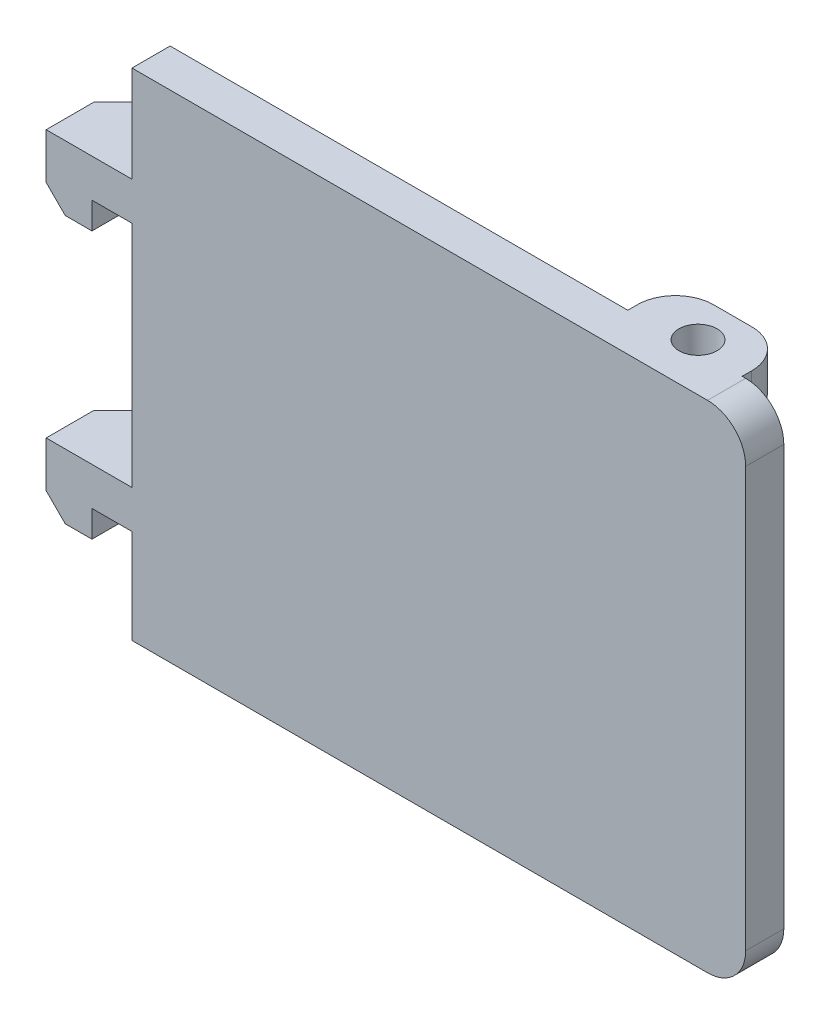
from build123d import *

# Parameters (mm, degrees)
SKETCH_2_W          = 32.183544672
SKETCH_2_H          = 26
EXTRUDE_1_DEPTH     = 2
FILLET_1_R          = 2
SKETCH_5_W          = 6
SKETCH_5_H          = 2
EXTRUDE_2_DEPTH     = 2.5
FILLET_2_R          = 2
SKETCH_6_R          = 1
CUT_EXTRUDE_3_DEPTH = 4
CUT_EXTRUDE_3_TAPER = 2
SKETCH_7_R          = 1
CUT_EXTRUDE_4_DEPTH = 4
CUT_EXTRUDE_4_TAPER = 2
SKETCH_8_W          = 4.5
SKETCH_8_H          = 2
EXTRUDE_3_DEPTH     = 2
SKETCH_10_W         = 2.4
SKETCH_10_H         = 1.4
EXTRUDE_4_DEPTH     = 2
EXTRUDE_4_2_DEPTH   = 2
SKETCH_11_W         = 8.5
SKETCH_11_H         = 2
EXTRUDE_5_DEPTH     = 2.5
CHAMFER_1_SIZE      = 2
CHAMFER_2_SIZE      = 1


with BuildPart() as part:
    # 草图2 → 凸台-拉伸1 (new body)
    with BuildSketch(Plane.XY):
        with Locations((-0.901029093, -19.434236018)):
            Rectangle(SKETCH_2_W, SKETCH_2_H)
    extrude(amount=EXTRUDE_1_DEPTH)

    # 圆角1
    fillet_1_edges = [part.edges().sort_by_distance(p)[0] for p in [
        (15.190743243, -32.434236018, 1),
        (15.190743243, -6.434236018, 1),
    ]]
    fillet(fillet_1_edges, radius=FILLET_1_R)

    # 草图5 → 凸台-拉伸2 (add)
    with BuildSketch(Plane(origin=(0, 0, 0), x_dir=(-1, 0, 0), z_dir=(0, 0, -1))):
        with Locations((-10.007198571, -7.434236018)):
            Rectangle(SKETCH_5_W, SKETCH_5_H)
        with Locations((-10.007198571, -31.434236018)):
            Rectangle(SKETCH_5_W, SKETCH_5_H)
    extrude(amount=EXTRUDE_2_DEPTH)

    # 圆角2
    fillet_2_edges = [part.edges().sort_by_distance(p)[0] for p in [
        (13.007198571, -7.434236018, -2.5),
        (7.007198571, -7.434236018, -2.5),
        (13.007198571, -31.434236018, -2.5),
        (7.007198571, -31.434236018, -2.5),
    ]]
    fillet(fillet_2_edges, radius=FILLET_2_R)

    # 草图6 → 切除-拉伸3 (cut)
    with BuildSketch(Plane.XZ.offset(32.434236018)):
        with Locations((10.190743244, -0.5)):
            Circle(SKETCH_6_R)
    extrude(amount=-CUT_EXTRUDE_3_DEPTH, taper=CUT_EXTRUDE_3_TAPER, mode=Mode.SUBTRACT)

    # 草图7 → 切除-拉伸4 (cut)
    with BuildSketch(Plane(origin=(0, -6.434236018, 0), x_dir=(1, 0, 0), z_dir=(0, 1, 0))):
        with Locations((10.190743243, 0.5)):
            Circle(SKETCH_7_R)
    extrude(amount=-CUT_EXTRUDE_4_DEPTH, taper=CUT_EXTRUDE_4_TAPER, mode=Mode.SUBTRACT)

    # 草图8 → 凸台-拉伸3 (add)
    with BuildSketch(Plane(origin=(0, 0, 0), x_dir=(-1, 0, 0), z_dir=(0, 0, -1))):
        with Locations((19.242801429, -12.484236018)):
            Rectangle(SKETCH_8_W, SKETCH_8_H)
        with Locations((19.242801429, -26.484236018)):
            Rectangle(SKETCH_8_W, SKETCH_8_H)
    extrude(amount=-EXTRUDE_3_DEPTH)



with BuildPart() as body_2:
    # 草图10 → 凸台-拉伸4 (new body)
    with BuildSketch(Plane(origin=(0, 0, 0), x_dir=(-1, 0, 0), z_dir=(0, 0, -1))):
        with Locations((20.292801429, -14.184236018)):
            Rectangle(SKETCH_10_W, SKETCH_10_H)
    extrude(amount=-EXTRUDE_4_DEPTH)


with BuildPart() as body_3:
    # 草图10 → Extrude 4 2 (new body)
    with BuildSketch(Plane(origin=(0, 0, 0), x_dir=(-1, 0, 0), z_dir=(0, 0, -1))):
        with Locations((20.292801429, -28.184236018)):
            Rectangle(SKETCH_10_W, SKETCH_10_H)
    extrude(amount=-EXTRUDE_4_2_DEPTH)


with BuildPart() as part_1:
    add(part.part)

    add(body_2.part)  # 凸台-拉伸5 merges body 2

    add(body_3.part)  # 凸台-拉伸5 merges body 3
    # 草图11 → 凸台-拉伸5 (add)
    with BuildSketch(Plane(origin=(0, 0, 0), x_dir=(-1, 0, 0), z_dir=(0, 0, -1))):
        with Locations((17.242801429, -12.484236018)):
            Rectangle(SKETCH_11_W, SKETCH_11_H)
        with Locations((17.242801429, -26.484236018)):
            Rectangle(SKETCH_11_W, SKETCH_11_H)
    extrude(amount=EXTRUDE_5_DEPTH)

    # 倒角1
    chamfer_1_edges = [part_1.edges().sort_by_distance(p)[0] for p in [
        (-21.492801429, -12.484236018, -2.5),
        (-12.992801429, -12.484236018, -2.5),
        (-21.492801429, -26.484236018, -2.5),
        (-12.992801429, -26.484236018, -2.5),
    ]]
    chamfer(chamfer_1_edges, length=CHAMFER_1_SIZE)

    # 倒角2
    chamfer_2_edges = [part_1.edges().sort_by_distance(p)[0] for p in [
        (-21.492801429, -14.884236018, 1),
        (-21.492801429, -28.884236018, 1),
    ]]
    chamfer(chamfer_2_edges, length=CHAMFER_2_SIZE)


solid = part_1.part
